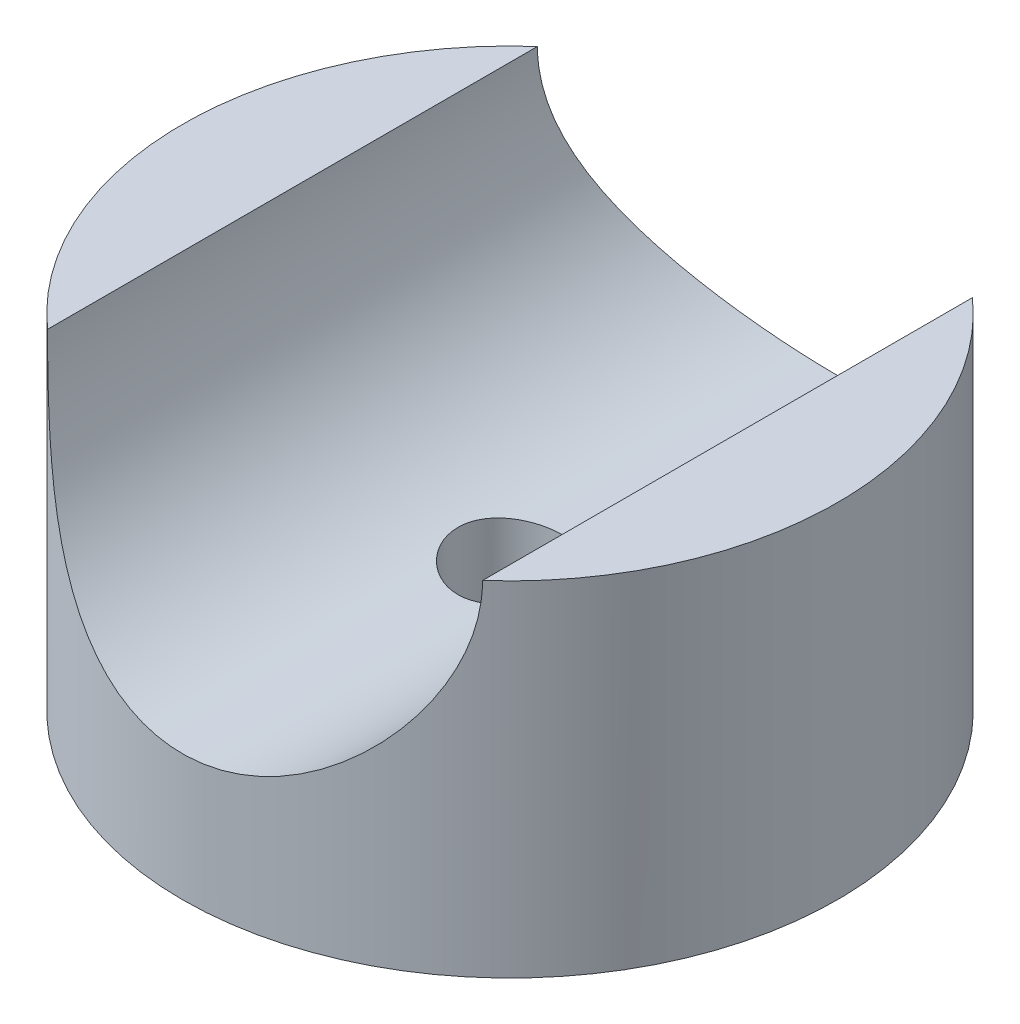
from build123d import *

# Parameters (mm, degrees)
SKETCH1_R                      = 31.75
BOSS_EXTRUDE1_DEPTH            = 33.3375
F_3_8_CLEARANCE_HOLE1_D        = 10.0838
CUT_EXTRUDE1_DEPTH             = 50.8
CUT_EXTRUDE1_DEPTH_BACK        = 50.8
SKETCH4_R                      = 21.082
TAP_DRILL_FOR_10_24_TAP1_D     = 3.7973
TAP_DRILL_FOR_10_24_TAP1_DEPTH = 19.05
TAP_DRILL_FOR_10_24_TAP1_TIP   = 1.140824014


with BuildPart() as part:
    # Sketch1 → Boss-Extrude1 (new body)
    with BuildSketch(Plane(origin=(0, 0, 0), x_dir=(1, 0, 0), z_dir=(0, 1, 0))):
        Circle(SKETCH1_R)
    extrude(amount=BOSS_EXTRUDE1_DEPTH)

    # 3_8 Clearance Hole1 (through all)
    with Locations(Plane(origin=(0, 33.3375, 0), x_dir=(1, 0, 0), z_dir=(0, 1, 0))):
        with Locations((0, 0)):
            Hole(F_3_8_CLEARANCE_HOLE1_D / 2)

    # Sketch4 → Cut-Extrude1 (cut, two sides: drawn at the far end of the back side and taken through both)
    with BuildSketch(Plane.XY.offset(-CUT_EXTRUDE1_DEPTH_BACK)):
        with Locations((0, 33.3375)):
            Circle(SKETCH4_R)
    extrude(amount=CUT_EXTRUDE1_DEPTH + CUT_EXTRUDE1_DEPTH_BACK, mode=Mode.SUBTRACT)

    # Tap Drill for _10-24 Tap1
    with Locations(Plane(origin=(0, 0, 0), x_dir=(-1, 0, 0), z_dir=(0, -1, 0))):
        with Locations((25.4, -9.525), (25.4, 9.525), (-25.4, 9.525), (-25.4, -9.525)):
            Hole(TAP_DRILL_FOR_10_24_TAP1_D / 2, depth=TAP_DRILL_FOR_10_24_TAP1_DEPTH)
            with Locations((0, 0, -(TAP_DRILL_FOR_10_24_TAP1_DEPTH + TAP_DRILL_FOR_10_24_TAP1_TIP / 2))):  # 118° drill point
                Cone(0, TAP_DRILL_FOR_10_24_TAP1_D / 2, TAP_DRILL_FOR_10_24_TAP1_TIP, mode=Mode.SUBTRACT)


solid = part.part
